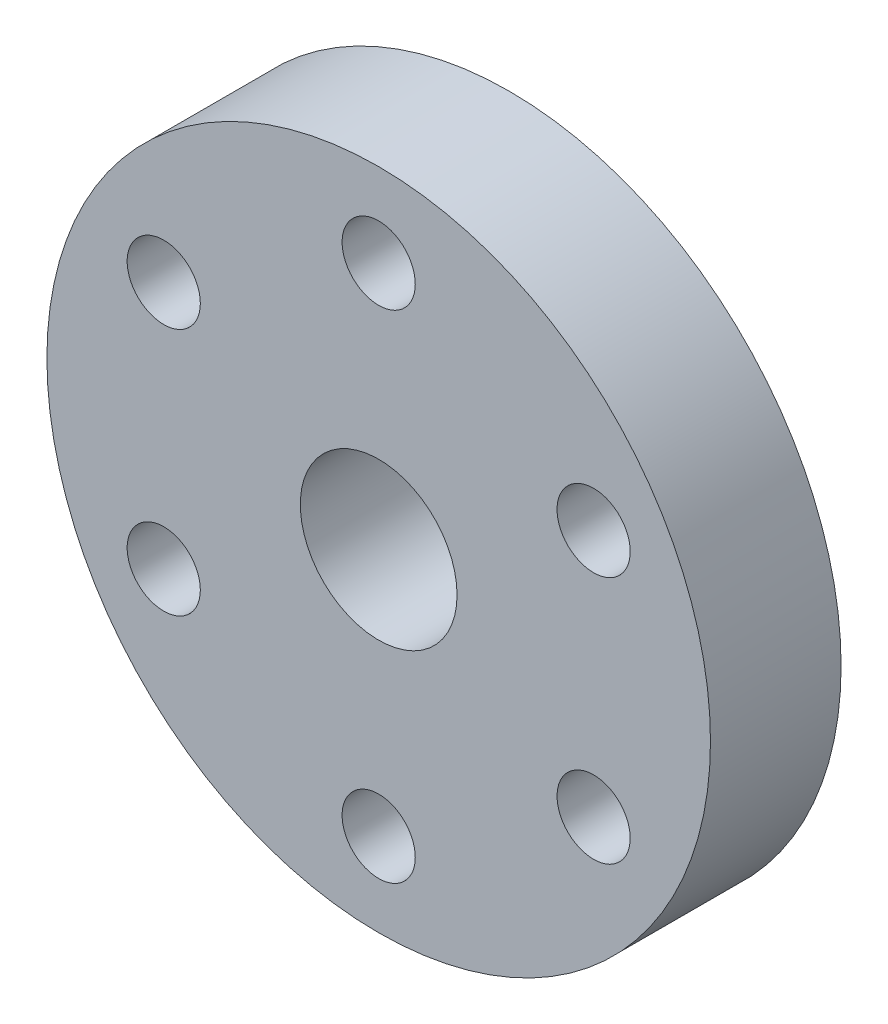
from build123d import *

# Parameters (mm, degrees)
SKETCH1_R           = 6
SKETCH1_R_2         = 3
BOSS_EXTRUDE1_DEPTH = 4.2
SKETCH2_R           = 12.7
SKETCH2_R_2         = 3
BOSS_EXTRUDE2_DEPTH = 5
SKETCH3_R           = 1.4
CUT_EXTRUDE1_DEPTH  = 13.7
SKETCH4_R           = 1.4
CUT_EXTRUDE2_DEPTH  = 5


with BuildPart() as part:
    # Sketch1 → Boss-Extrude1 (new body)
    with BuildSketch(Plane.XY):
        Circle(SKETCH1_R)
        Circle(SKETCH1_R_2, mode=Mode.SUBTRACT)
    extrude(amount=BOSS_EXTRUDE1_DEPTH)

    # Sketch2 → Boss-Extrude2 (add)
    with BuildSketch(Plane.XY.offset(4.2)):
        Circle(SKETCH2_R)
        Circle(SKETCH2_R_2, mode=Mode.SUBTRACT)
    extrude(amount=BOSS_EXTRUDE2_DEPTH)

    # Sketch3 → Cut-Extrude1 (cut, through all)
    with BuildSketch(Plane(origin=(0, 0, 0), x_dir=(1, 0, 0), z_dir=(0, 1, 0))):
        with Locations((0, -2.1)):
            Circle(SKETCH3_R)
    extrude(amount=-CUT_EXTRUDE1_DEPTH, mode=Mode.SUBTRACT)

    # Sketch4 → Cut-Extrude2 (cut)
    with BuildSketch(Plane.XY.offset(9.2)):
        with Locations((0, 9.5)):
            Circle(SKETCH4_R)
        with Locations((8.227241336, 4.75)):
            Circle(SKETCH4_R)
        with Locations((8.227241336, -4.75)):
            Circle(SKETCH4_R)
        with Locations((0, -9.5)):
            Circle(SKETCH4_R)
        with Locations((-8.227241336, -4.75)):
            Circle(SKETCH4_R)
        with Locations((-8.227241336, 4.75)):
            Circle(SKETCH4_R)
    extrude(amount=-CUT_EXTRUDE2_DEPTH, mode=Mode.SUBTRACT)


solid = part.part
